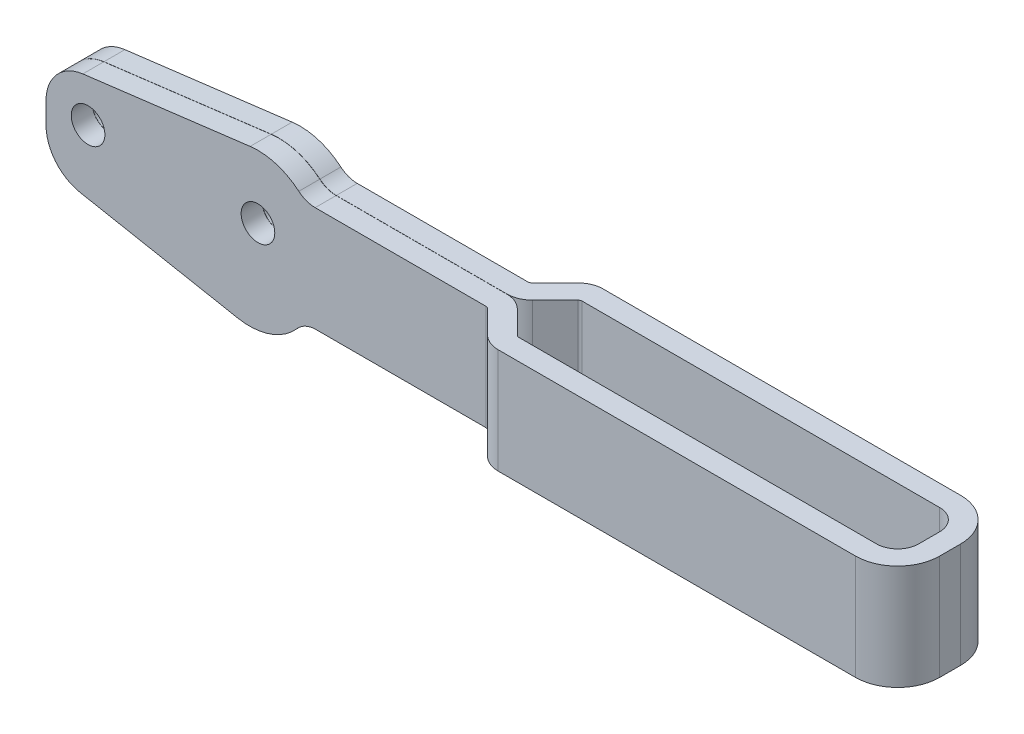
from build123d import *

# Parameters (mm, degrees)
SKETCH1_W               = 133.35
SKETCH1_H               = 15.875
BASE_EXTRUDE_DEPTH      = 7.9375
CUT_EXTRUDE1_DEPTH      = 16.875
FILLET5_R               = 0.635
FILLET6_R               = 3.81
FILLET7_R               = 3.175
FILLET8_R               = 6.35
FILLET9_R               = 6.35
FILLET10_R              = 6.35
BOSS_EXTRUDE3_DEPTH     = 6.35
FILLET11_R              = 3.81
SKETCH7_R               = 2.54
CUT_EXTRUDE5_DEPTH      = 12.1125
SKETCH8_W               = 76.190653673
SKETCH8_H               = 0.0254
CUT_EXTRUDE6_DEPTH      = 4.175
CUT_EXTRUDE6_DEPTH_BACK = 21.447
FILLET12_R              = 3.81
FILLET13_R              = 3.81


with BuildPart() as part:
    # Sketch1 → Base-Extrude (new body, symmetric)
    with BuildSketch(Plane.XY):
        with Locations((66.675, 7.9375)):
            Rectangle(SKETCH1_W, SKETCH1_H)
    extrude(amount=BASE_EXTRUDE_DEPTH, both=True)

    # Sketch3 → Cut-Extrude1 (cut, through all)
    with BuildSketch(Plane(origin=(0, 15.875, 0), x_dir=(-1, 0, 0), z_dir=(0, 1, 0))):
        Polygon((-72.752628061, -4.7625), (-130.175, -4.7625), (-130.175, 4.7625), (-72.752628061, 4.7625), (-67.990128061, 0), align=None)
        Polygon((1.24743597, -3.175), (-66.675, -3.175), (-73.371059662, -9.871059662), (1.24743597, -9.871059662), align=None)
        Polygon((1.24743597, 3.175), (-66.675, 3.175), (-73.371059662, 9.871059662), (1.24743597, 9.871059662), align=None)
    extrude(amount=-CUT_EXTRUDE1_DEPTH, mode=Mode.SUBTRACT)

    # Fillet5
    fillet5_edges = [part.edges().sort_by_distance(p)[0] for p in [
        (72.752628061, 7.9375, -4.7625),
        (72.752628061, 7.9375, 4.7625),
        (66.675, 7.9375, 3.175),
        (66.675, 7.9375, -3.175),
    ]]
    fillet(fillet5_edges, radius=FILLET5_R)

    # Fillet6
    fillet6_edges = [part.edges().sort_by_distance(p)[0] for p in [
        (71.4375, 7.9375, -7.9375),
        (71.4375, 7.9375, 7.9375),
    ]]
    fillet(fillet6_edges, radius=FILLET6_R)

    # Fillet7
    fillet7_edges = [part.edges().sort_by_distance(p)[0] for p in [
        (130.175, 7.9375, -4.7625),
        (130.175, 7.9375, 4.7625),
    ]]
    fillet(fillet7_edges, radius=FILLET7_R)

    # Fillet8
    fillet8_edges = [part.edges().sort_by_distance(p)[0] for p in [
        (133.35, 7.9375, 7.9375),
        (133.35, 7.9375, -7.9375),
    ]]
    fillet(fillet8_edges, radius=FILLET8_R)

    # Fillet9
    fillet9_edges = [part.edges().sort_by_distance(p)[0] for p in [
        (0, 15.875, 0),
    ]]
    fillet(fillet9_edges, radius=FILLET9_R)

    # Fillet10
    fillet10_edges = [part.edges().sort_by_distance(p)[0] for p in [
        (0, 0, 0),
    ]]
    fillet(fillet10_edges, radius=FILLET10_R)

    # Sketch6 → Boss-Extrude3 (add)
    with BuildSketch(Plane.XY.offset(3.175)):
        with BuildLine():
            Line((5.564108911, 15.826180461), (30.825163366, 18.976770691))
            ThreePointArc((30.825163366, 18.976770691), (39.943880119, 14.786551928), (40.249024971, 4.755808431))
            ThreePointArc((40.249024971, 4.755808431), (36.72434383, -2.446073762), (28.949130797, -4.404784191))
            Line((28.949130797, -4.404784191), (5.165376283, 0.111477206))
            ThreePointArc((5.165376283, 0.111477206), (1.458943846, 2.300300048), (0, 6.35))
            Line((0, 6.35), (0, 9.525))
            ThreePointArc((0, 9.525), (1.590120358, 13.728099546), (5.564108911, 15.826180461))
        make_face()
    extrude(amount=-BOSS_EXTRUDE3_DEPTH)

    # Fillet11
    fillet11_edges = [part.edges().sort_by_distance(p)[0] for p in [
        (38.862, 0, 0),
        (39.103515829, 15.875, 0),
    ]]
    fillet(fillet11_edges, radius=FILLET11_R)

    # Sketch7 → Cut-Extrude5 (cut, through all)
    with BuildSketch(Plane.XY.offset(3.175)):
        with Locations((6.35, 9.525)):
            Circle(SKETCH7_R)
        with Locations((32.004, 9.525)):
            Circle(SKETCH7_R)
    extrude(amount=-CUT_EXTRUDE5_DEPTH, mode=Mode.SUBTRACT)

    # Sketch8 → Cut-Extrude6 (cut, two sides)
    with BuildSketch(Plane(origin=(0, 15.875, 0), x_dir=(-1, 0, 0), z_dir=(0, 1, 0))) as cut_extrude6_sk:
        with Locations((-34.920326837, 0)):
            Rectangle(SKETCH8_W, SKETCH8_H)
    extrude(amount=CUT_EXTRUDE6_DEPTH, mode=Mode.SUBTRACT)
    extrude(cut_extrude6_sk.sketch, amount=-CUT_EXTRUDE6_DEPTH_BACK, mode=Mode.SUBTRACT)

    # Fillet12
    fillet12_edges = [part.edges().sort_by_distance(p)[0] for p in [
        (68.002828061, 7.9375, 0.0127),
    ]]
    fillet(fillet12_edges, radius=FILLET12_R)

    # Fillet13
    fillet13_edges = [part.edges().sort_by_distance(p)[0] for p in [
        (68.002828061, 7.9375, -0.0127),
    ]]
    fillet(fillet13_edges, radius=FILLET13_R)


solid = part.part
